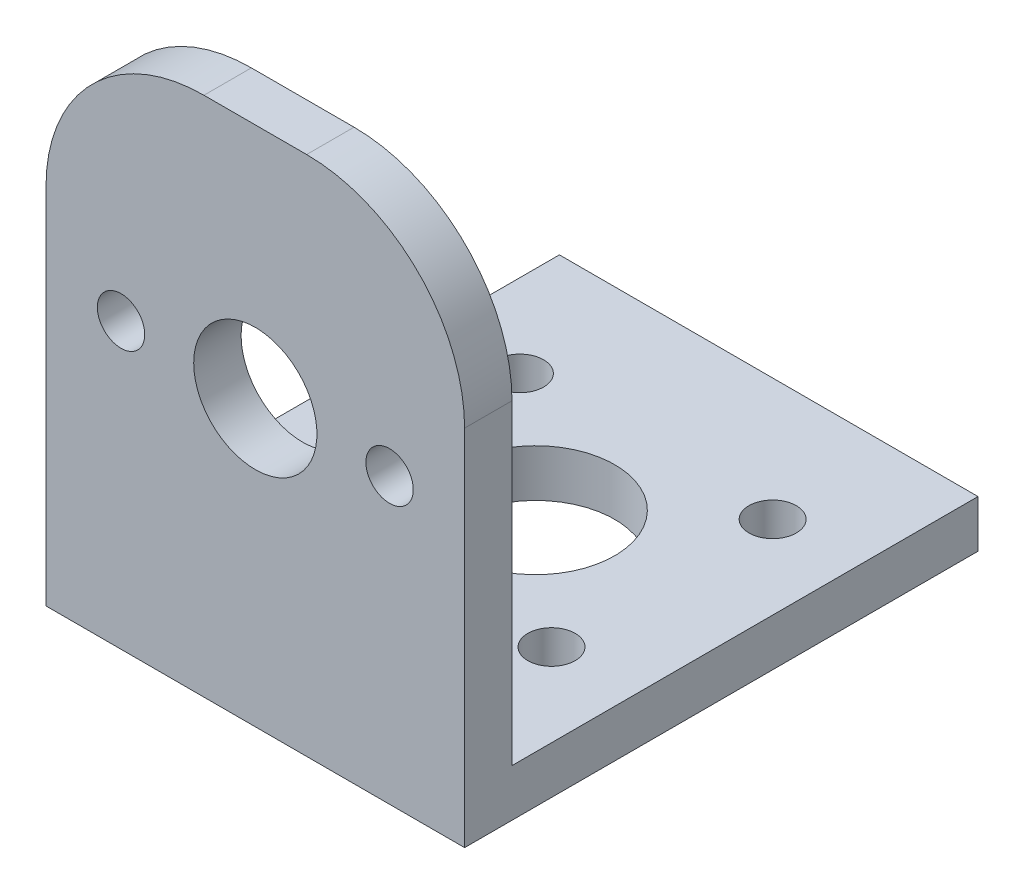
from build123d import *

# Parameters (mm, degrees)
BOSS_EXTRUDE1_DEPTH = 26.5
SKETCH2_R           = 3.9
SKETCH2_R_2         = 1.5
CUT_EXTRUDE1_DEPTH  = 4
SKETCH3_R           = 5
SKETCH3_R_2         = 1.5
CUT_EXTRUDE2_DEPTH  = 4


with BuildPart() as part:
    # Sketch1 → Boss-Extrude1 (new body)
    with BuildSketch(Plane(origin=(0, 0, 0), x_dir=(0, 0, -1), z_dir=(1, 0, 0))):
        Polygon((-3, -3), (29.5, -3), (29.5, 0), (0, 0), (0, 30), (-3, 30), align=None)
    extrude(amount=BOSS_EXTRUDE1_DEPTH)

    # Sketch2 → Cut-Extrude1 (cut, through all)
    with BuildSketch(Plane(origin=(0, 0, 0), x_dir=(-1, 0, 0), z_dir=(0, 0, -1))):
        with Locations((-13.25, 15)):
            Circle(SKETCH2_R)
        with Locations((-4.75, 15)):
            Circle(SKETCH2_R_2)
        with Locations((-21.75, 15)):
            Circle(SKETCH2_R_2)
        with BuildLine():
            ThreePointArc((-26.5, 20), (-23.571067812, 27.071067812), (-16.5, 30))
            Line((-16.5, 30), (-26.5, 30))
            Line((-26.5, 30), (-26.5, 20))
        make_face()
        with BuildLine():
            Line((0, 30), (-10, 30))
            ThreePointArc((-10, 30), (-2.928932188, 27.071067812), (0, 20))
            Line((0, 20), (0, 30))
        make_face()
    extrude(amount=-CUT_EXTRUDE1_DEPTH, mode=Mode.SUBTRACT)

    # Sketch3 → Cut-Extrude2 (cut, through all)
    with BuildSketch(Plane(origin=(0, 0, 0), x_dir=(1, 0, 0), z_dir=(0, 1, 0))):
        with Locations((13.25, 14.75)):
            Circle(SKETCH3_R)
        with Locations((21.25, 21.75)):
            Circle(SKETCH3_R_2)
        with Locations((21.25, 7.75)):
            Circle(SKETCH3_R_2)
        with Locations((5.25, 21.75)):
            Circle(SKETCH3_R_2)
        with Locations((5.25, 7.75)):
            Circle(SKETCH3_R_2)
    extrude(amount=-CUT_EXTRUDE2_DEPTH, mode=Mode.SUBTRACT)


solid = part.part
